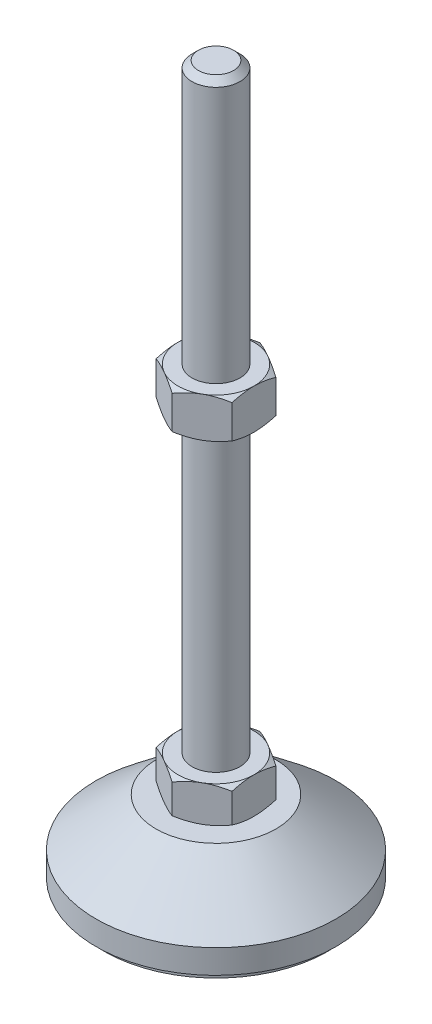
from build123d import *

# Parameters (mm, degrees)
EXTRUDE_1_DEPTH = 9
EXTRUDE_2_DEPTH = 10


with BuildPart() as part:
    # Эскиз1 → Повернуть1 (revolve)
    with BuildSketch(Plane.XY, mode=Mode.PRIVATE) as revolve_1_sk:
        Polygon((0, 0), (-28, 0), (-28, 2), (-30, 2), (-30, 8), (-15, 20), (-6, 20), (-6, 29), (-6, 177.4), (-4.4, 179), (0, 179), align=None)
    revolve(revolve_1_sk.sketch.rotate(Axis((0, 0, 0), (0, 1, 0)), 180), axis=Axis((0, 0, 0), (0, 1, 0)))  # turned: the seam where the file's is

    # Эскиз2 → Бобышка-Вытянуть1 (add)
    with BuildSketch(Plane(origin=(0, 20, 0), x_dir=(1, 0, 0), z_dir=(0, 1, 0))):
        Polygon((0, 10.969655115), (-9.5, 5.484827557), (-9.5, -5.484827557), (0, -10.969655115), (9.5, -5.484827557), (9.5, 5.484827557), align=None)
    extrude(amount=EXTRUDE_1_DEPTH)

    # Эскиз3 → Бобышка-Вытянуть2 (add)
    with BuildSketch(Plane(origin=(0, 103.2, 0), x_dir=(1, 0, 0), z_dir=(0, 1, 0))):
        Polygon((9.5, 5.484827557), (0, 10.969655115), (-9.5, 5.484827557), (-9.5, -5.484827557), (0, -10.969655115), (9.5, -5.484827557), align=None)
    extrude(amount=EXTRUDE_2_DEPTH)

    # Эскиз4 → Вырез-Повернуть2 (revolve, cut)
    with BuildSketch(Plane.XY, mode=Mode.PRIVATE) as cut_revolve_2_sk:
        Polygon((-18.160254038, 113.2), (-9.5, 113.2), (-18.160254038, 108.2), align=None)
        Polygon((-18.160254038, 103.2), (-18.160254038, 108.2), (-9.5, 103.2), align=None)
        Polygon((-17.294228634, 29), (-17.294228634, 24.5), (-9.5, 29), align=None)
        Polygon((-17.294228634, 24.5), (-17.294228634, 20), (-9.5, 20), align=None)
    revolve(cut_revolve_2_sk.sketch.rotate(Axis((0, 179, 0), (0, -1, 0)), 180), axis=Axis((0, 179, 0), (0, -1, 0)), mode=Mode.SUBTRACT)  # turned: the seam where the file's is


solid = part.part
